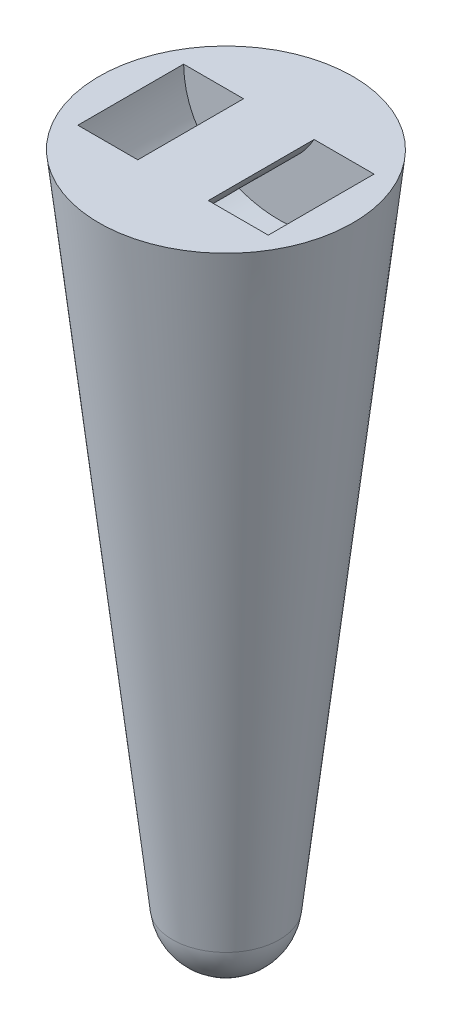
from build123d import *

# Parameters (mm, degrees)
ENL_V_MAT_EXTRU_1_DEPTH      = 7.5
ENL_V_MAT_EXTRU_1_DEPTH_BACK = 7.5
BOSS_EXTRU_1_REACH           = 27.5
ECHELLE1_SCALE               = 0.8


with BuildPart() as part:
    # Esquisse1 → R_volution1 (revolve)
    with BuildSketch(Plane.XY):
        with BuildLine():
            Line((0, 0), (0, 100))
            Line((0, 100), (-18, 100))
            Line((-18, 100), (-7.593007693, 6.792401612))
            ThreePointArc((-7.593007693, 6.792401612), (-5.093880777, 1.945904787), (0, 0))
        make_face()
    revolve(axis=Axis((0, 0, 0), (0, 1, 0)))

    # Esquisse2 → Enl_v. mat.-Extru.1 (cut, two sides)
    with BuildSketch(Plane.XY) as enl_v_mat_extru_1_sk:
        with BuildLine():
            Line((-13.5, 100), (13.5, 100))
            add(Edge.make_bspline(
                [(-13.5, 100), (-13.291113541, 83.520875666), (13.291113541, 83.520875666), (13.5, 100)],
                knots=[0, 0, 0, 0, 1, 1, 1, 1], degree=3))
        make_face()
    extrude(amount=ENL_V_MAT_EXTRU_1_DEPTH, mode=Mode.SUBTRACT)
    extrude(enl_v_mat_extru_1_sk.sketch, amount=-ENL_V_MAT_EXTRU_1_DEPTH_BACK, mode=Mode.SUBTRACT)

    # Esquisse3 → Boss.-Extru.1 (add, up to next)
    with BuildSketch(Plane.XY.offset(-7.5), mode=Mode.PRIVATE) as boss_extru_1_sk1:
        with BuildLine():
            Line((-5, 100), (5, 100))
            add(Edge.make_bspline(
                [(-5, 100), (0, 91.498247822), (5, 100)],
                knots=[0, 0, 0, 1, 1, 1], degree=2))
        make_face()
    boss_extru_1_tool1 = extrude(boss_extru_1_sk1.sketch, amount=BOSS_EXTRU_1_REACH, mode=Mode.PRIVATE) - part.part
    add(boss_extru_1_tool1.solids().sort_by_distance((0, 98.29965, -7.5))[0])


with BuildPart() as part_1:
    # Echelle1: scaled about (-4e-09, 62.219241992, 3e-09)
    add(part.part.scale(ECHELLE1_SCALE).moved(Location((-1e-09, 12.443848398, 1e-09))))


solid = part_1.part
